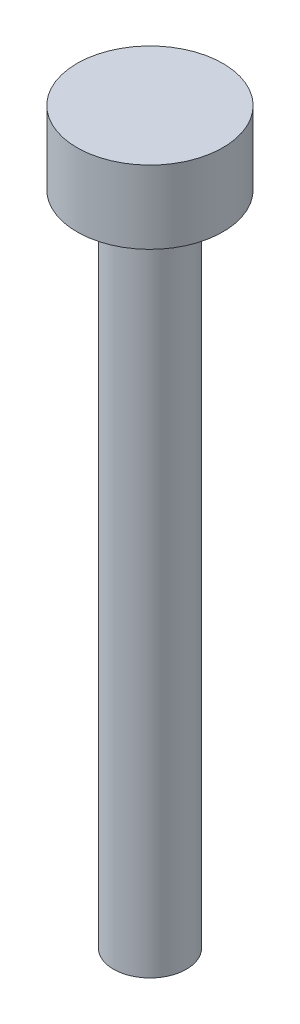
from build123d import *


with BuildPart() as part:
    # Sketch1 → Revolve1 (revolve)
    with BuildSketch(Plane.XY):
        Polygon((0, 0), (0, 22.86), (-1.27, 22.86), (-1.27, 25.4), (1.27, 25.4), (1.27, 0), align=None)
    revolve(axis=Axis((1.27, 25.4, 0), (0, -1, 0)))


solid = part.part
